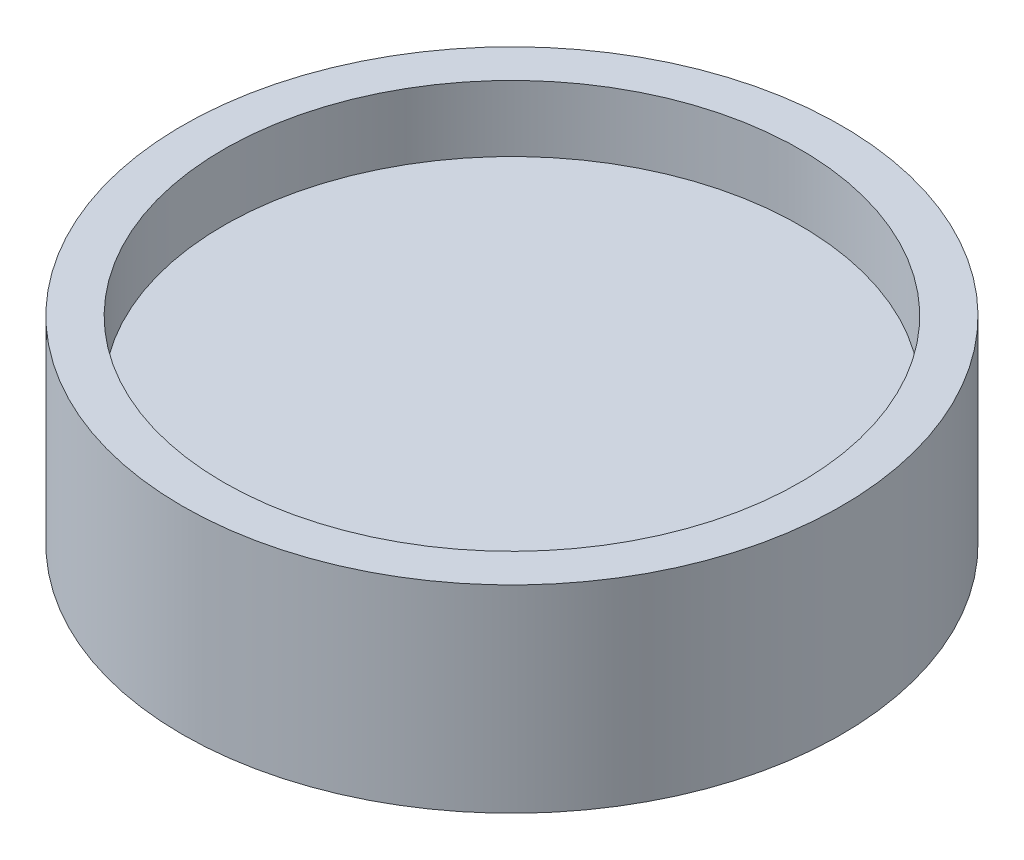
from build123d import *

# Parameters (mm, degrees)
ESQUISSE1_R             = 40
BOSS_EXTRU_1_DEPTH      = 24
ESQUISSE2_R             = 35
ENL_V_MAT_EXTRU_1_DEPTH = 8
ESQUISSE3_R             = 35
ENL_V_MAT_EXTRU_2_DEPTH = 8


with BuildPart() as part:
    # Esquisse1 → Boss.-Extru.1 (new body)
    with BuildSketch(Plane(origin=(0, 0, 0), x_dir=(1, 0, 0), z_dir=(0, 1, 0))):
        Circle(ESQUISSE1_R)
    extrude(amount=BOSS_EXTRU_1_DEPTH)

    # Esquisse2 → Enlèv. mat.-Extru.1 (cut)
    with BuildSketch(Plane(origin=(0, 24, 0), x_dir=(1, 0, 0), z_dir=(0, 1, 0))):
        Circle(ESQUISSE2_R)
    extrude(amount=-ENL_V_MAT_EXTRU_1_DEPTH, mode=Mode.SUBTRACT)

    # Esquisse3 → Enlèv. mat.-Extru.2 (cut)
    with BuildSketch(Plane.XZ):
        Circle(ESQUISSE3_R)
    extrude(amount=-ENL_V_MAT_EXTRU_2_DEPTH, mode=Mode.SUBTRACT)


solid = part.part
